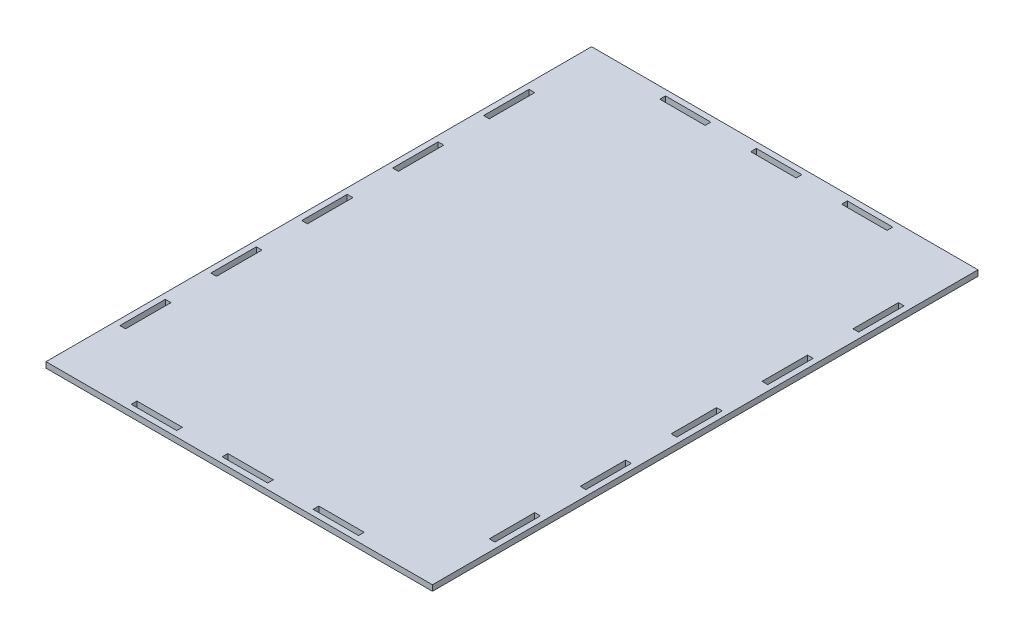
from build123d import *

# Parameters (mm, degrees)
SKETCH1_W           = 215.9
SKETCH1_H           = 304.8
SKETCH1_W_2         = 25.4
SKETCH1_H_2         = 3.175
SKETCH1_W_3         = 3.175
SKETCH1_H_3         = 25.4
BOSS_EXTRUDE1_DEPTH = 1.5875


with BuildPart() as part:
    # Sketch1 → Boss-Extrude1 (new body, symmetric)
    with BuildSketch(Plane(origin=(0, 0, 0), x_dir=(1, 0, 0), z_dir=(0, 1, 0))):
        Rectangle(SKETCH1_W, SKETCH1_H)
        with Locations((0, 147.6375)):
            Rectangle(SKETCH1_W_2, SKETCH1_H_2, mode=Mode.SUBTRACT)
        with Locations((50.8, 147.6375)):
            Rectangle(SKETCH1_W_2, SKETCH1_H_2, mode=Mode.SUBTRACT)
        with Locations((-50.8, 147.6375)):
            Rectangle(SKETCH1_W_2, SKETCH1_H_2, mode=Mode.SUBTRACT)
        with Locations((-50.8, -147.6375)):
            Rectangle(SKETCH1_W_2, SKETCH1_H_2, mode=Mode.SUBTRACT)
        with Locations((0, -147.6375)):
            Rectangle(SKETCH1_W_2, SKETCH1_H_2, mode=Mode.SUBTRACT)
        with Locations((50.8, -147.6375)):
            Rectangle(SKETCH1_W_2, SKETCH1_H_2, mode=Mode.SUBTRACT)
        with Locations((103.1875, 0)):
            Rectangle(SKETCH1_W_3, SKETCH1_H_3, mode=Mode.SUBTRACT)
        with Locations((103.1875, 50.8)):
            Rectangle(SKETCH1_W_3, SKETCH1_H_3, mode=Mode.SUBTRACT)
        with Locations((103.1875, 101.6)):
            Rectangle(SKETCH1_W_3, SKETCH1_H_3, mode=Mode.SUBTRACT)
        with Locations((103.1875, -50.8)):
            Rectangle(SKETCH1_W_3, SKETCH1_H_3, mode=Mode.SUBTRACT)
        with Locations((103.1875, -101.6)):
            Rectangle(SKETCH1_W_3, SKETCH1_H_3, mode=Mode.SUBTRACT)
        with Locations((-103.1875, 101.6)):
            Rectangle(SKETCH1_W_3, SKETCH1_H_3, mode=Mode.SUBTRACT)
        with Locations((-103.1875, 50.8)):
            Rectangle(SKETCH1_W_3, SKETCH1_H_3, mode=Mode.SUBTRACT)
        with Locations((-103.1875, 0)):
            Rectangle(SKETCH1_W_3, SKETCH1_H_3, mode=Mode.SUBTRACT)
        with Locations((-103.1875, -50.8)):
            Rectangle(SKETCH1_W_3, SKETCH1_H_3, mode=Mode.SUBTRACT)
        with Locations((-103.1875, -101.6)):
            Rectangle(SKETCH1_W_3, SKETCH1_H_3, mode=Mode.SUBTRACT)
    extrude(amount=BOSS_EXTRUDE1_DEPTH, both=True)


solid = part.part
